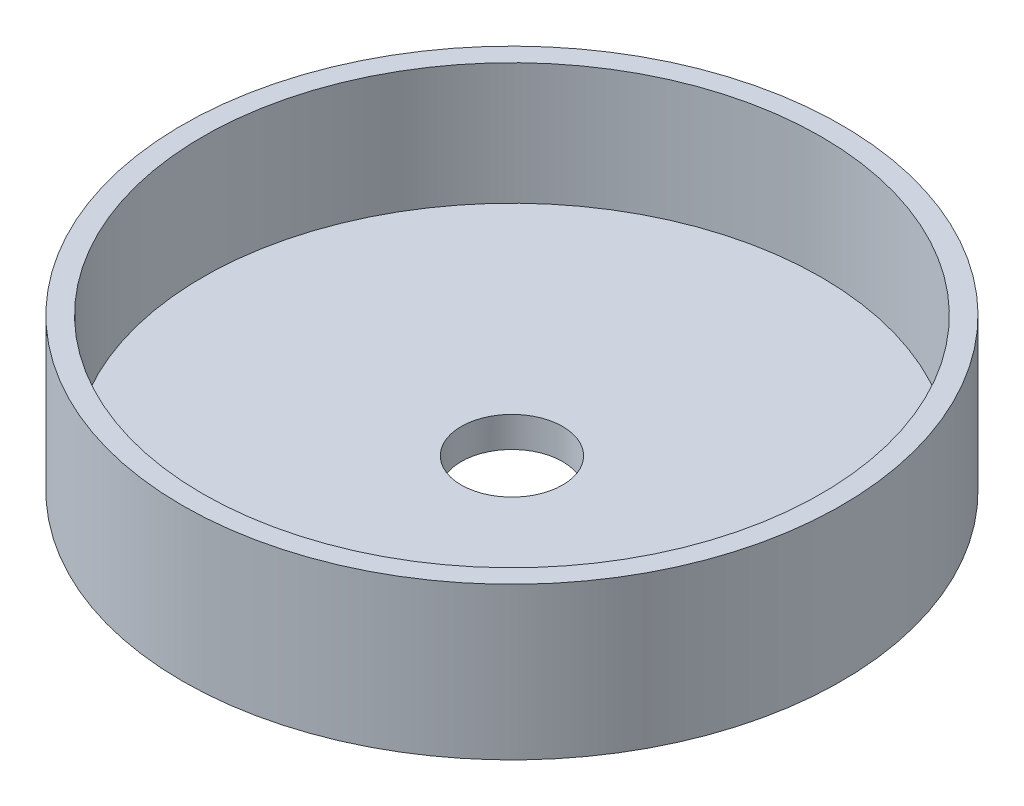
from build123d import *

# Parameters (mm, degrees)
IZIM1_R                     = 32.5
Y_KSEKLIK_EKSTR_ZYON2_DEPTH = 15
IZIM3_R                     = 30.5
KES_EKSTR_ZYON1_DEPTH       = 12
IZIM4_R                     = 5
KES_EKSTR_ZYON2_DEPTH       = 12


with BuildPart() as part:
    # Çizim1 → Yükseklik-Ekstrüzyon2 (new body)
    with BuildSketch(Plane(origin=(0, 0, 0), x_dir=(1, 0, 0), z_dir=(0, 1, 0))):
        Circle(IZIM1_R)
    extrude(amount=Y_KSEKLIK_EKSTR_ZYON2_DEPTH)

    # Çizim3 → Kes-Ekstrüzyon1 (cut)
    with BuildSketch(Plane(origin=(0, 15, 0), x_dir=(1, 0, 0), z_dir=(0, 1, 0))):
        Circle(IZIM3_R)
    extrude(amount=-KES_EKSTR_ZYON1_DEPTH, mode=Mode.SUBTRACT)

    # Çizim4 → Kes-Ekstrüzyon2 (cut)
    with BuildSketch(Plane.XZ):
        Circle(IZIM4_R)
    extrude(amount=-KES_EKSTR_ZYON2_DEPTH, mode=Mode.SUBTRACT)


solid = part.part
